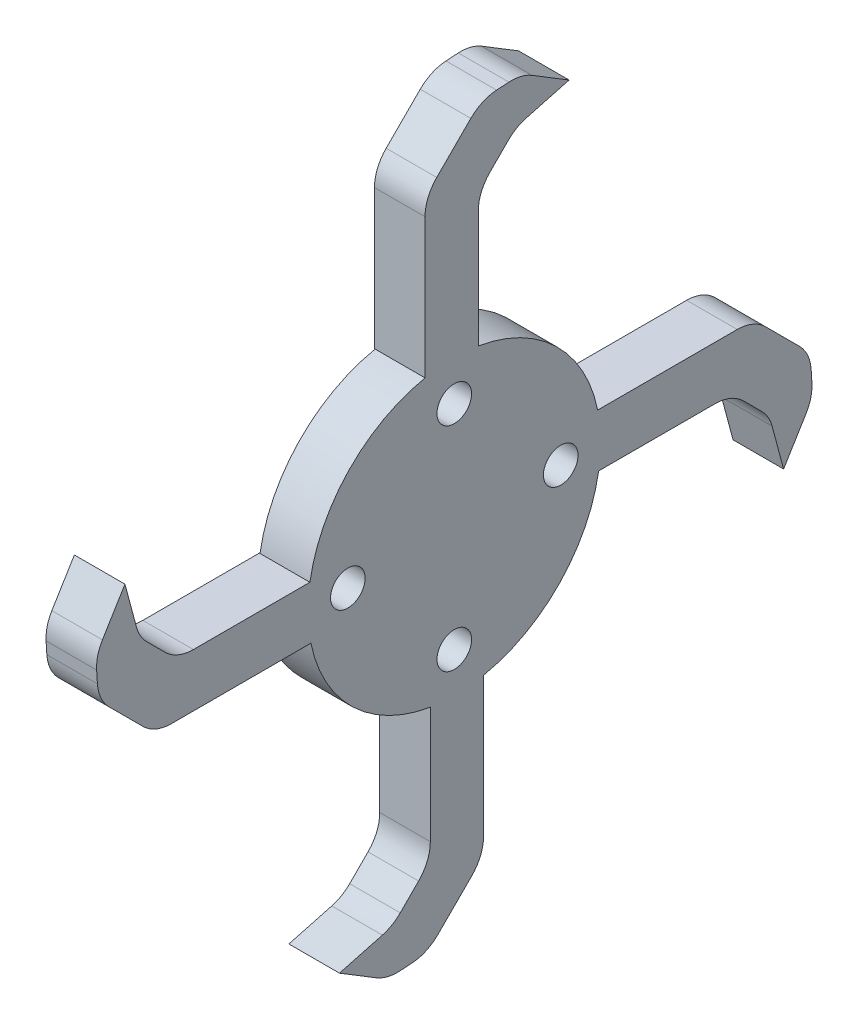
from build123d import *

# Parameters (mm, degrees)
SKETCH1_R                = 13.97
SKETCH1_R_2              = 1.651
BOSS_EXTRUDE1_DEPTH      = 4.7625
LEG1_DEPTH               = 4.826
FILLET2_R                = 3.81
CIRPATTERN1_COUNT        = 4
FILLET2_OF_CIRPATTERN1_R = 3.81


with BuildPart() as part:
    # Sketch1 → Boss-Extrude1 (new body)
    with BuildSketch(Plane(origin=(0, 0, 0), x_dir=(0, 0, -1), z_dir=(1, 0, 0))):
        Circle(SKETCH1_R)
        with Locations((-10.16, 0)):
            Circle(SKETCH1_R_2, mode=Mode.SUBTRACT)
        with Locations((0, 10.16)):
            Circle(SKETCH1_R_2, mode=Mode.SUBTRACT)
        with Locations((10.16, 0)):
            Circle(SKETCH1_R_2, mode=Mode.SUBTRACT)
        with Locations((0, -10.16)):
            Circle(SKETCH1_R_2, mode=Mode.SUBTRACT)
    extrude(amount=BOSS_EXTRUDE1_DEPTH)

    # Sketch2 → leg1 (add)
    with BuildSketch(Plane(origin=(4.7625, 0, 0), x_dir=(0, 0, -1), z_dir=(1, 0, 0))):
        with BuildLine():
            Line((13.688198848, 2.791793742), (28.585533284, 2.791793742))
            Line((28.585533284, 2.791793742), (33.973686957, -2.596359931))
            Line((33.973686957, -2.596359931), (34.21186075, -6.406359931))
            Line((34.21186075, -6.406359931), (31.434612733, -10.960308707))
            Line((31.434612733, -10.960308707), (30.073430836, -5.880308707))
            Line((30.073430836, -5.880308707), (26.481328387, -2.288206258))
            Line((26.481328387, -2.288206258), (13.781328387, -2.288206258))
            ThreePointArc((13.781328387, -2.288206258), (13.967653047, 0.256063207), (13.688198848, 2.791793742))
        make_face()
    leg1 = extrude(amount=-LEG1_DEPTH)

    # Fillet2
    fillet2_edges = [part.edges().sort_by_distance(p)[0] for p in [
        (2.3495, 2.791793742, -28.585533284),
        (2.3495, -2.596359931, -33.973686957),
        (2.3495, -6.406359931, -34.21186075),
        (2.3495, -5.880308707, -30.073430836),
        (2.3495, -2.288206258, -26.481328387),
    ]]
    fillet(fillet2_edges, radius=FILLET2_R)

    # CirPattern1: leg1 ×4 about axis
    cirpattern1_axis = Axis((0, 0, 0), (1, 0, 0))
    for i in range(1, CIRPATTERN1_COUNT):
        add(leg1.rotate(cirpattern1_axis, i * 360 / CIRPATTERN1_COUNT))

    # Fillet2 of CirPattern1
    fillet2_of_cirpattern1_edges = [part.edges().sort_by_distance(p)[0] for p in [
        (2.3495, 28.585533284, 2.791793742),
        (2.3495, 33.973686957, -2.596359931),
        (2.3495, 34.21186075, -6.406359931),
        (2.3495, 30.073430836, -5.880308707),
        (2.3495, 26.481328387, -2.288206258),
        (2.3495, -2.791793742, 28.585533284),
        (2.3495, 2.596359931, 33.973686957),
        (2.3495, 6.406359931, 34.21186075),
        (2.3495, 5.880308707, 30.073430836),
        (2.3495, 2.288206258, 26.481328387),
        (2.3495, -28.585533284, -2.791793742),
        (2.3495, -33.973686957, 2.596359931),
        (2.3495, -34.21186075, 6.406359931),
        (2.3495, -30.073430836, 5.880308707),
        (2.3495, -26.481328387, 2.288206258),
    ]]
    fillet(fillet2_of_cirpattern1_edges, radius=FILLET2_OF_CIRPATTERN1_R)


solid = part.part
